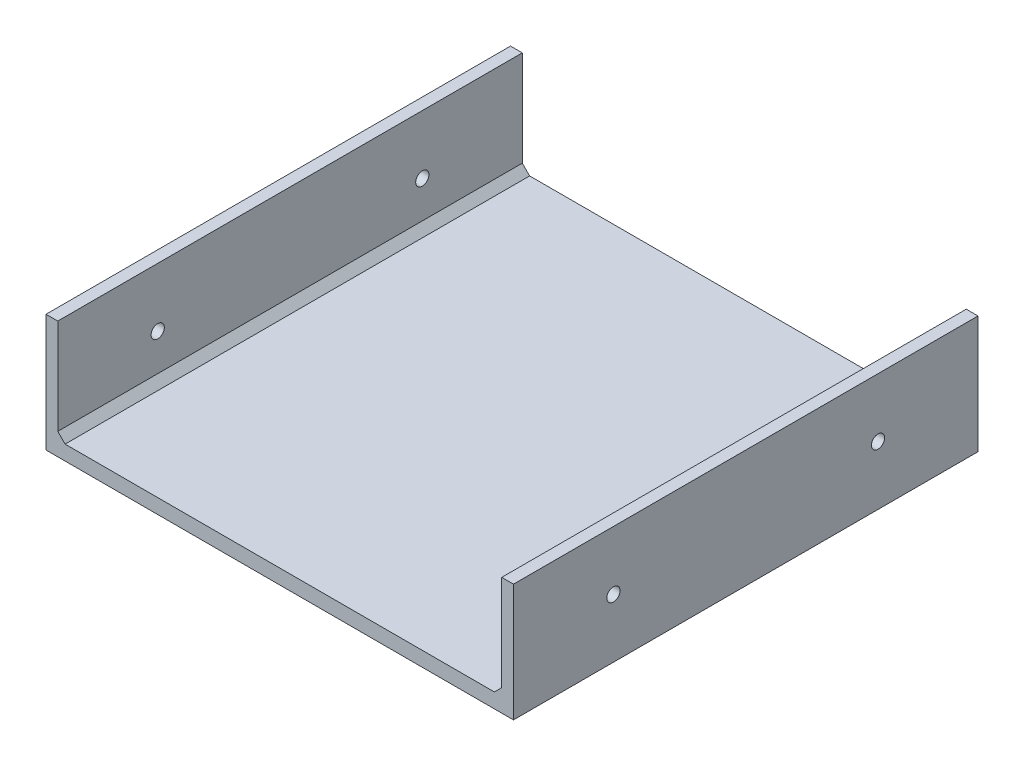
from build123d import *

# Parameters (mm, degrees)
SKETCH1_W            = 159
SKETCH1_H            = 158
BOSS_EXTRUDE1_DEPTH  = 5
SKETCH4_W            = 4
SKETCH4_H            = 158
BOSS_EXTRUDE2_DEPTH  = 35
M4_CLEARANCE_HOLE1_D = 4.5
CHAMFER2_SIZE        = 2.5


with BuildPart() as part:
    # Sketch1 → Boss-Extrude1 (new body)
    with BuildSketch(Plane(origin=(0, 0, 0), x_dir=(1, 0, 0), z_dir=(0, 1, 0))):
        with Locations((0, -79)):
            Rectangle(SKETCH1_W, SKETCH1_H)
    extrude(amount=BOSS_EXTRUDE1_DEPTH)

    # Sketch4 → Boss-Extrude2 (add)
    with BuildSketch(Plane(origin=(0, 5, 0), x_dir=(1, 0, 0), z_dir=(0, 1, 0))):
        with Locations((77.5, -79)):
            Rectangle(SKETCH4_W, SKETCH4_H)
    boss_extrude2 = extrude(amount=BOSS_EXTRUDE2_DEPTH)

    # M4 Clearance Hole1 (through all)
    with Locations(Plane.ZY.offset(-75.5)):
        with Locations((124, 20), (34, 20)):
            m4_clearance_hole1 = Hole(M4_CLEARANCE_HOLE1_D / 2)

    # Mirror2: Boss-Extrude2, M4 Clearance Hole1 across plane
    add(boss_extrude2.mirror(Plane.ZY))
    add(m4_clearance_hole1.mirror(Plane.ZY), mode=Mode.SUBTRACT)

    # Chamfer2
    chamfer2_edges = [part.edges().sort_by_distance(p)[0] for p in [
        (75.5, 5, 79),
        (-75.5, 5, 79),
    ]]
    chamfer(chamfer2_edges, length=CHAMFER2_SIZE)


solid = part.part
